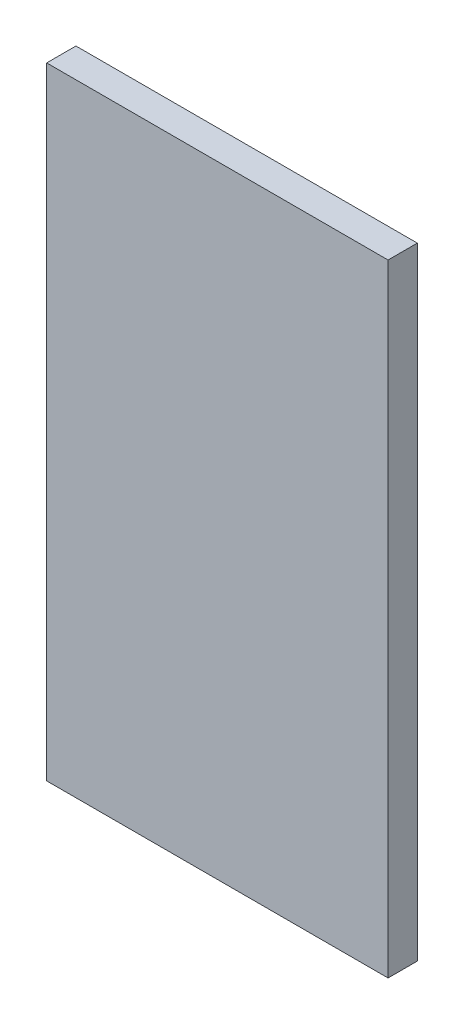
from build123d import *

# Parameters (mm, degrees)
SKETCH2_W           = 70
SKETCH2_H           = 127.5
BOSS_EXTRUDE1_DEPTH = 6


with BuildPart() as part:
    # Sketch2 → Boss-Extrude1 (new body)
    with BuildSketch(Plane.XY):
        Rectangle(SKETCH2_W, SKETCH2_H)
    extrude(amount=BOSS_EXTRUDE1_DEPTH)


solid = part.part
